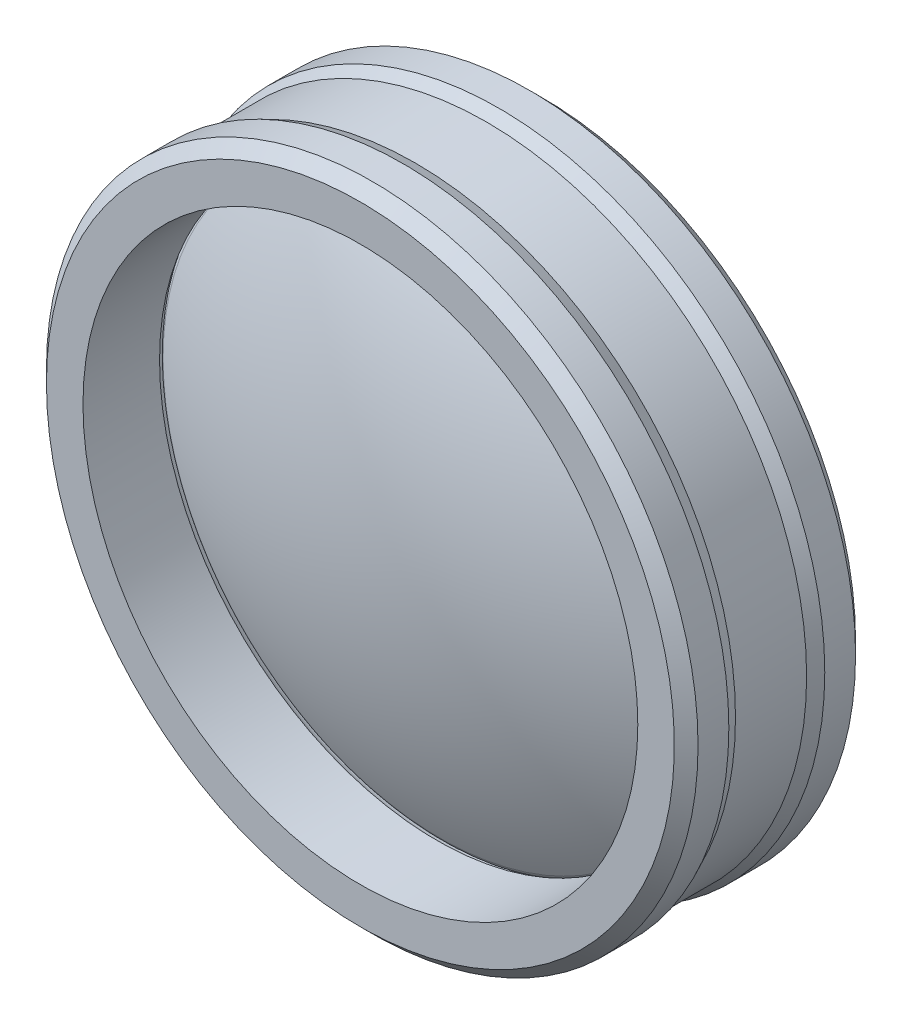
from build123d import *

# Parameters (mm, degrees)
FILLET1_R     = 1
CHAMFER1_SIZE = 1


with BuildPart() as part:
    # Sketch1 → Revolve3 (revolve)
    with BuildSketch(Plane(origin=(0, 0, 0), x_dir=(0, 0, -1), z_dir=(1, 0, 0))):
        with BuildLine():
            Line((-6.698729811, 0), (6.698729811, 0))
            ThreePointArc((6.698729811, 0), (4.995021125, 12.940952255), (0, 25))
            ThreePointArc((0, 25), (-4.995021125, 12.940952255), (-6.698729811, 0))
        make_face()
    revolve(axis=Axis((0, 0, 86.575961886), (0, 0, -1)))

    # Fillet1
    fillet1_edges = [part.edges().sort_by_distance(p)[0] for p in [
        (0, -25, 0),
    ]]
    fillet(fillet1_edges, radius=FILLET1_R)


with BuildPart() as body_2:
    # Sketch2 → Revolve5 (revolve)
    with BuildSketch(Plane(origin=(0, 0, 0), x_dir=(0, 0, -1), z_dir=(1, 0, 0))):
        with BuildLine():
            Line((-1.183594451, 23.402744778), (-7.644169322, 23.402744778))
            Line((-7.644169322, 23.402744778), (-7.644169322, 27.485014913))
            Line((-7.644169322, 27.485014913), (-4.046690664, 27.485014913))
            Line((-4.046690664, 27.485014913), (-3, 27))
            Line((-3, 27), (3, 27))
            Line((3, 27), (4.046690664, 27.485014913))
            Line((4.046690664, 27.485014913), (7.644169322, 27.485014913))
            Line((7.644169322, 27.485014913), (7.644169322, 23.402744778))
            Line((7.644169322, 23.402744778), (1.183594451, 23.402744778))
            ThreePointArc((1.183594451, 23.402744778), (0, 24.207470779), (-1.183594451, 23.402744778))
        make_face()
    revolve(axis=Axis((0, 0, 0), (0, 0, -1)))

    # Chamfer1
    chamfer1_edges = [body_2.edges().sort_by_distance(p)[0] for p in [
        (0, -27.485014913, 7.644169322),
        (0, -27.485014913, -7.644169322),
    ]]
    chamfer(chamfer1_edges, length=CHAMFER1_SIZE)


solid = Compound([part.part, body_2.part])
